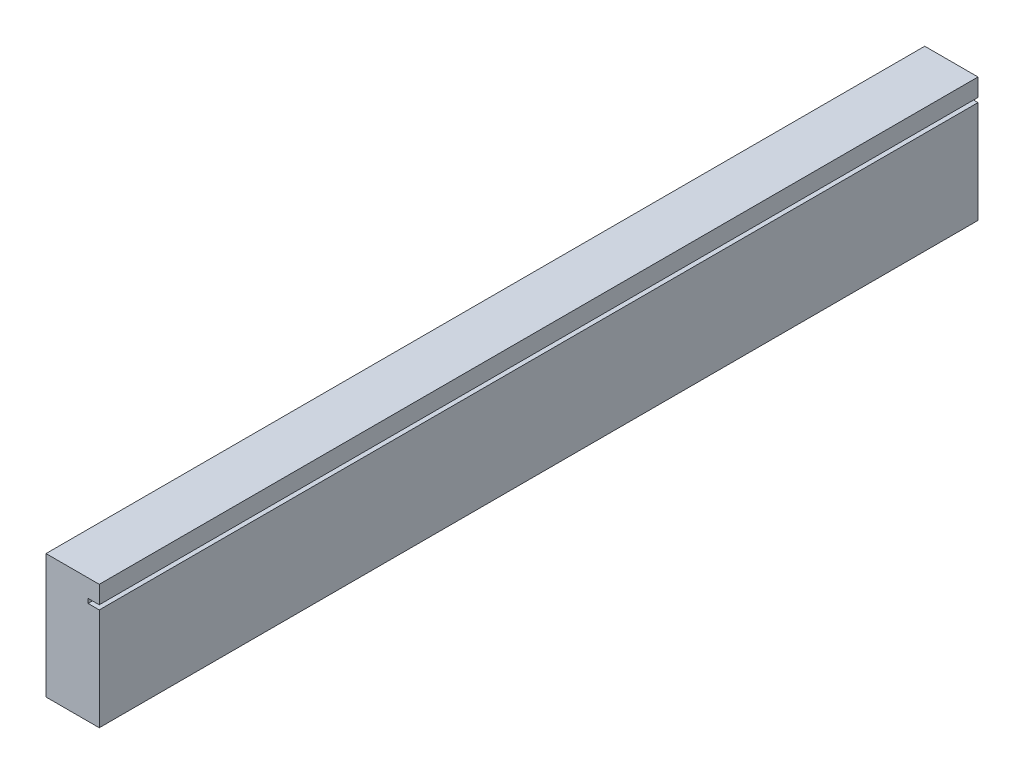
from build123d import *

# Parameters (mm, degrees)
SKETCH1_W               = 38.1
SKETCH1_H               = 88.9
BOSS_EXTRUDE1_DEPTH     = 314.325
SKETCH2_W               = 8
SKETCH2_H               = 3.175
CUT_EXTRUDE1_DEPTH      = 315.325
CUT_EXTRUDE1_DEPTH_BACK = 315.325


with BuildPart() as part:
    # Sketch1 → Boss-Extrude1 (new body, symmetric)
    with BuildSketch(Plane.XY):
        Rectangle(SKETCH1_W, SKETCH1_H)
    extrude(amount=BOSS_EXTRUDE1_DEPTH, both=True)

    # Sketch2 → Cut-Extrude1 (cut, two sides)
    with BuildSketch(Plane.XY) as cut_extrude1_sk:
        with Locations((15.05, 30.1625)):
            Rectangle(SKETCH2_W, SKETCH2_H)
    extrude(amount=CUT_EXTRUDE1_DEPTH, mode=Mode.SUBTRACT)
    extrude(cut_extrude1_sk.sketch, amount=-CUT_EXTRUDE1_DEPTH_BACK, mode=Mode.SUBTRACT)


solid = part.part
